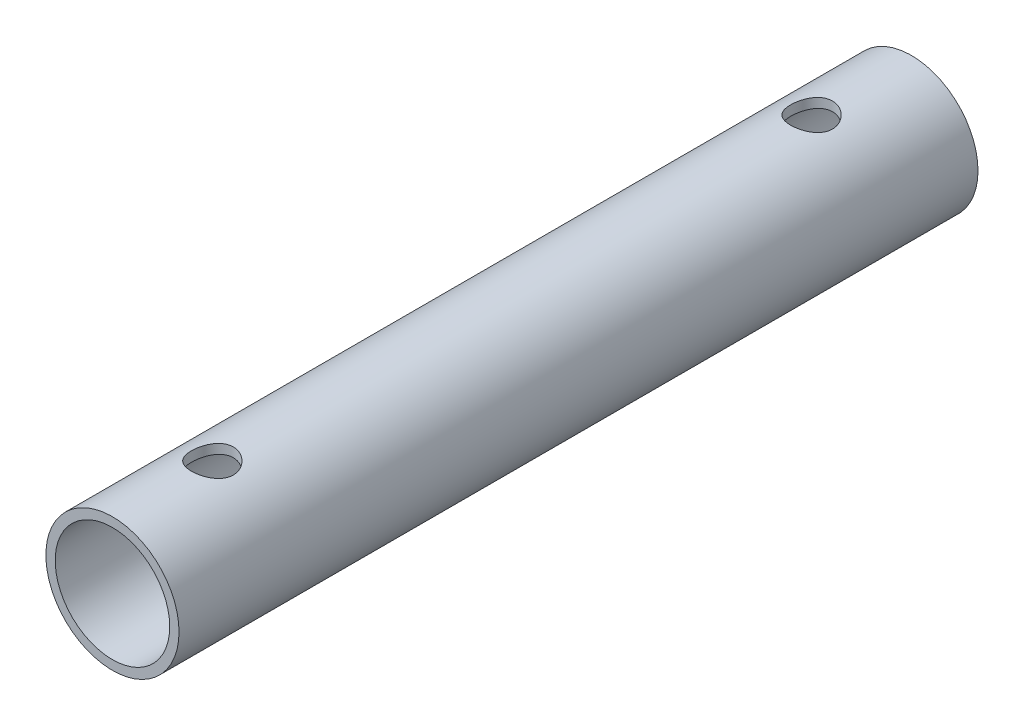
from build123d import *

# Parameters (mm, degrees)
SKETCH1_R               = 6.35
SKETCH1_R_2             = 5.461
EXTRUDE1_DEPTH          = 76.2
CUT_EXTRUDE1_DEPTH      = 38.1
CUT_EXTRUDE1_DEPTH_BACK = 38.1
SKETCH2_R               = 2


with BuildPart() as part:
    # Sketch1 → Extrude1 (new body)
    with BuildSketch(Plane.XY):
        Circle(SKETCH1_R)
        Circle(SKETCH1_R_2, mode=Mode.SUBTRACT)
    extrude(amount=EXTRUDE1_DEPTH)

    # Sketch2 → Cut-Extrude1 (cut, two sides: drawn at the far end of the back side and taken through both)
    with BuildSketch(Plane(origin=(0, 0, 0), x_dir=(1, 0, 0), z_dir=(0, 1, 0)).offset(-CUT_EXTRUDE1_DEPTH_BACK)):
        with Locations((0, -9.525)):
            Circle(SKETCH2_R)
        with Locations((0, -66.675)):
            Circle(SKETCH2_R)
    extrude(amount=CUT_EXTRUDE1_DEPTH + CUT_EXTRUDE1_DEPTH_BACK, mode=Mode.SUBTRACT)


solid = part.part
